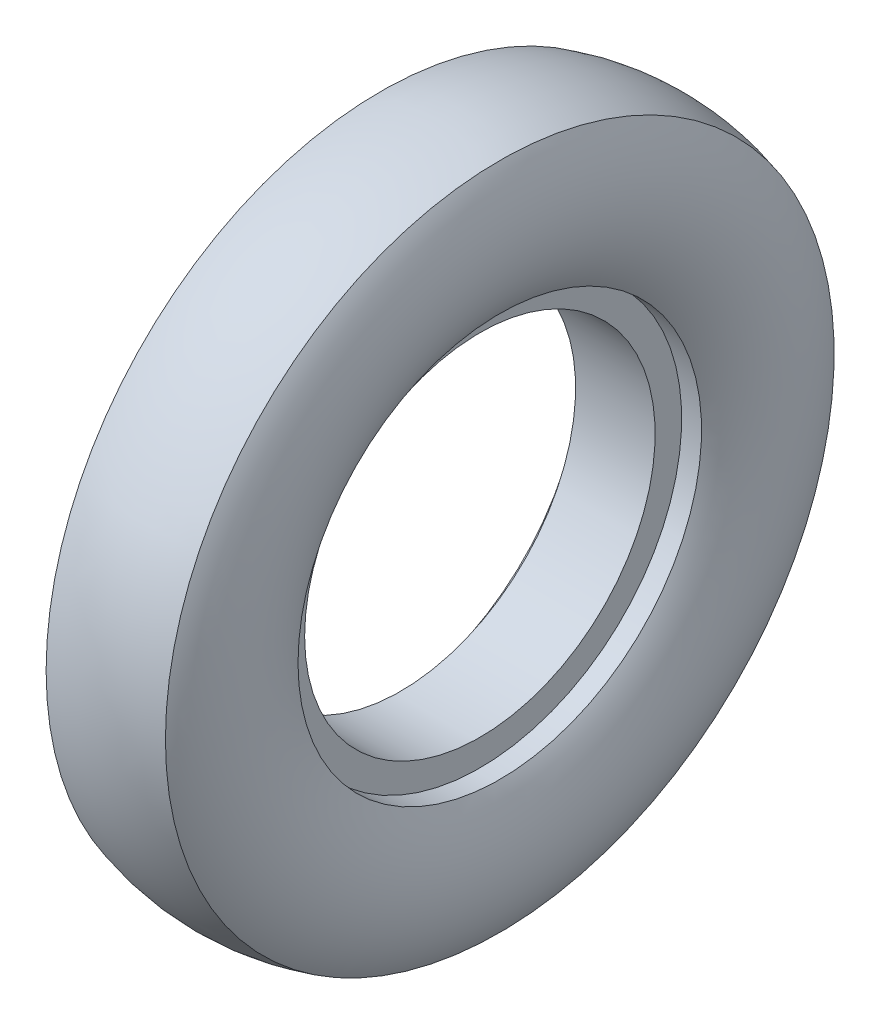
from build123d import *


with BuildPart() as part:
    # Sketch1 → Revolve1 (revolve)
    with BuildSketch(Plane(origin=(0, 0, 0), x_dir=(1, 0, 0), z_dir=(0, 1, 0))):
        with BuildLine():
            Line((-0.923496983, 13.220158419), (5.076503017, 13.220158419))
            Line((5.076503017, 13.220158419), (5.076503017, 15.220158419))
            Line((5.076503017, 15.220158419), (6.576503017, 15.220158419))
            ThreePointArc((6.576503017, 15.220158419), (8.076503017, 20.220158419), (6.576503017, 25.220158419))
            ThreePointArc((6.576503017, 25.220158419), (2.076503017, 25.884128338), (-2.423496983, 25.220158419))
            ThreePointArc((-2.423496983, 25.220158419), (-3.923496983, 20.220158419), (-2.423496983, 15.220158419))
            Line((-2.423496983, 15.220158419), (-0.923496983, 15.220158419))
            Line((-0.923496983, 15.220158419), (-0.923496983, 13.220158419))
        make_face()
    revolve(axis=Axis((-18.907532969, 0, 0), (1, 0, 0)))


solid = part.part
